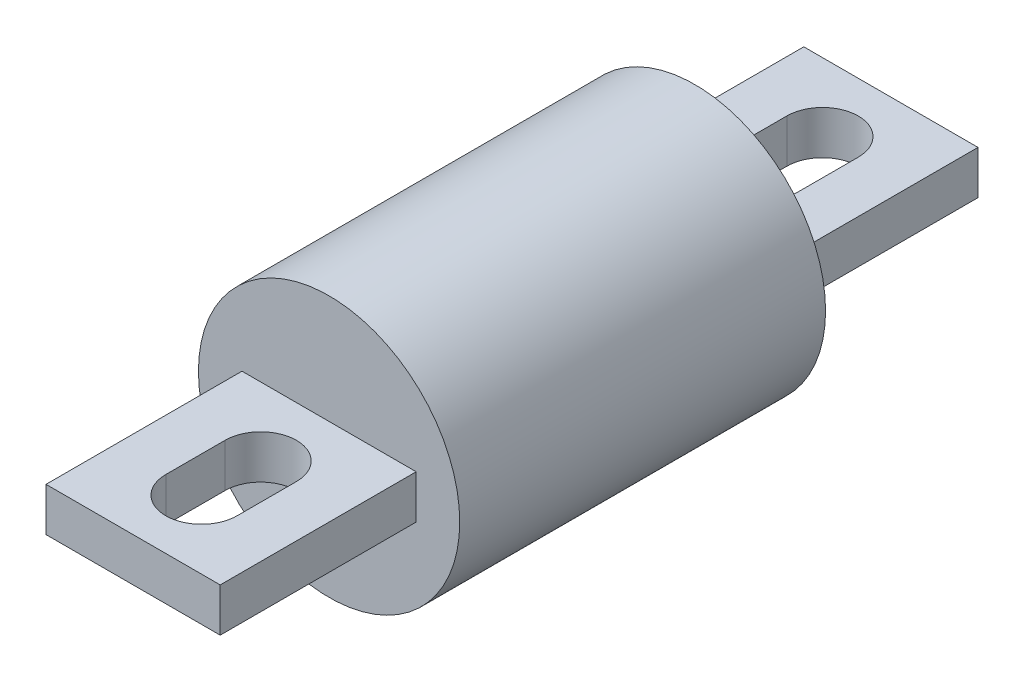
from build123d import *

# Parameters (mm, degrees)
FUSE_DEPTH      = 26.67
FUSE_DEPTH_BACK = 26.67
SKETCH1_R       = 19.05
SKETCH2_W       = 25.4
SKETCH2_H       = 28.575
TAB_DEPTH       = 3.175


with BuildPart() as part:
    # Sketch1 → Fuse (new, two sides: drawn at the far end of the back side and taken through both)
    with BuildSketch(Plane.XY.offset(-FUSE_DEPTH_BACK)):
        Circle(SKETCH1_R)
    extrude(amount=FUSE_DEPTH + FUSE_DEPTH_BACK)

    # Sketch2 → Tab (add, symmetric)
    with BuildSketch(Plane(origin=(0, 0, 0), x_dir=(1, 0, 0), z_dir=(0, 1, 0))):
        with Locations((0, 40.9575)):
            Rectangle(SKETCH2_W, SKETCH2_H)
        with BuildLine():
            Line((-5.207, 36.6395), (-5.207, 45.2755))
            ThreePointArc((-5.207, 45.2755), (0, 50.4825), (5.207, 45.2755))
            Line((5.207, 45.2755), (5.207, 36.6395))
            ThreePointArc((5.207, 36.6395), (0, 31.4325), (-5.207, 36.6395))
        make_face(mode=Mode.SUBTRACT)
    tab = extrude(amount=TAB_DEPTH, both=True)

    # Tab Mirror: Tab across plane
    add(tab.mirror(Plane.XY))


solid = part.part
